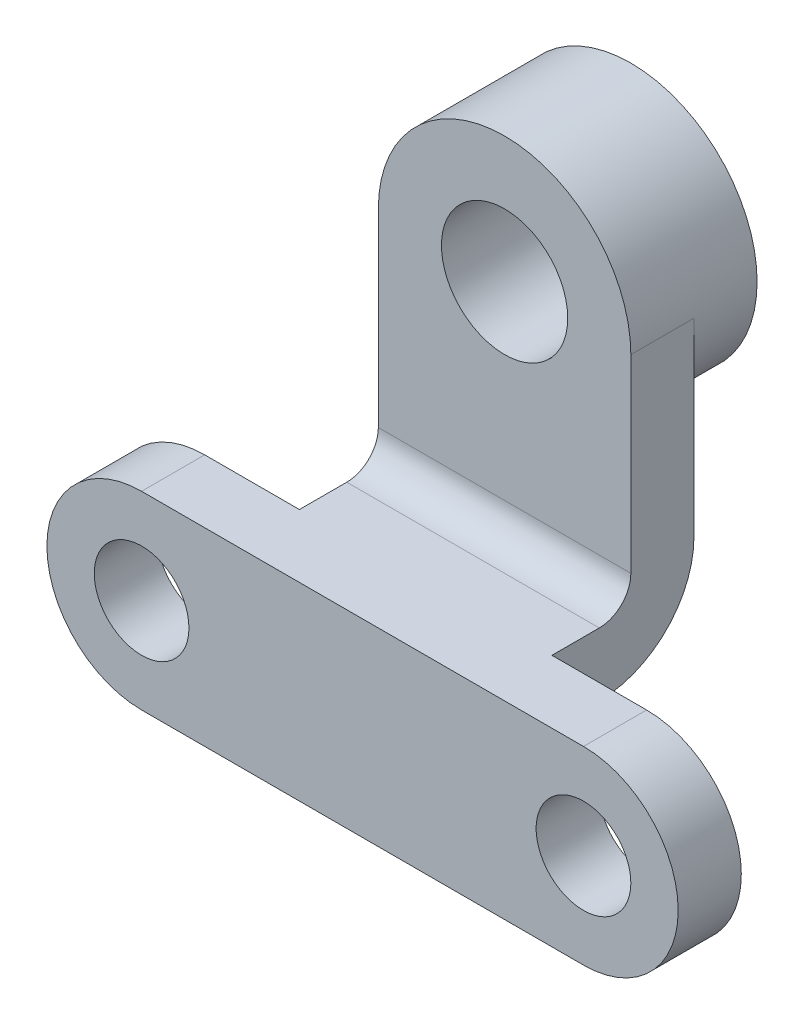
from build123d import *

# Parameters (mm, degrees)
SKETCH1_R           = 19.05
BOSS_EXTRUDE1_DEPTH = 25.4
SKETCH2_W           = 101.6
SKETCH2_H           = 25.4
BOSS_EXTRUDE2_DEPTH = 57.15
SKETCH5_W           = 101.6
SKETCH5_H           = 25.4
BOSS_EXTRUDE3_DEPTH = 88.9
SKETCH6_R           = 50.8
BOSS_EXTRUDE4_DEPTH = 50.8
SKETCH7_R           = 25.4
CUT_EXTRUDE1_DEPTH  = 50.8
FILLET1_R           = 12.7
FILLET2_R           = 38.1


with BuildPart() as part:
    # Sketch1 → Boss-Extrude1 (new body)
    with BuildSketch(Plane.XY):
        with BuildLine():
            Line((-88.9, 38.1), (88.9, 38.1))
            ThreePointArc((88.9, 38.1), (127, 0), (88.9, -38.1))
            Line((88.9, -38.1), (-88.9, -38.1))
            ThreePointArc((-88.9, -38.1), (-127, 0), (-88.9, 38.1))
        make_face()
        with Locations((-88.9, 0)):
            Circle(SKETCH1_R, mode=Mode.SUBTRACT)
        with Locations((88.9, 0)):
            Circle(SKETCH1_R, mode=Mode.SUBTRACT)
    extrude(amount=-BOSS_EXTRUDE1_DEPTH)

    # Sketch2 → Boss-Extrude2 (add)
    with BuildSketch(Plane(origin=(0, 0, -25.4), x_dir=(-1, 0, 0), z_dir=(0, 0, -1))):
        with Locations((0, 25.4)):
            Rectangle(SKETCH2_W, SKETCH2_H)
    extrude(amount=BOSS_EXTRUDE2_DEPTH)

    # Sketch5 → Boss-Extrude3 (add)
    with BuildSketch(Plane(origin=(0, 38.1, 0), x_dir=(1, 0, 0), z_dir=(0, 1, 0))):
        with Locations((0, 69.85)):
            Rectangle(SKETCH5_W, SKETCH5_H)
    extrude(amount=BOSS_EXTRUDE3_DEPTH)

    # Sketch6 → Boss-Extrude4 (add)
    with BuildSketch(Plane.XY.offset(-57.15)):
        with Locations((0, 127)):
            Circle(SKETCH6_R)
    extrude(amount=-BOSS_EXTRUDE4_DEPTH)

    # Sketch7 → Cut-Extrude1 (cut)
    with BuildSketch(Plane.XY.offset(-57.15)):
        with Locations((0, 127)):
            Circle(SKETCH7_R)
    extrude(amount=-CUT_EXTRUDE1_DEPTH, mode=Mode.SUBTRACT)

    # Fillet1
    fillet1_edges = [part.edges().sort_by_distance(p)[0] for p in [
        (0, 38.1, -57.15),
    ]]
    fillet(fillet1_edges, radius=FILLET1_R)

    # Fillet2
    fillet2_edges = [part.edges().sort_by_distance(p)[0] for p in [
        (0, 12.7, -82.55),
    ]]
    fillet(fillet2_edges, radius=FILLET2_R)


solid = part.part
